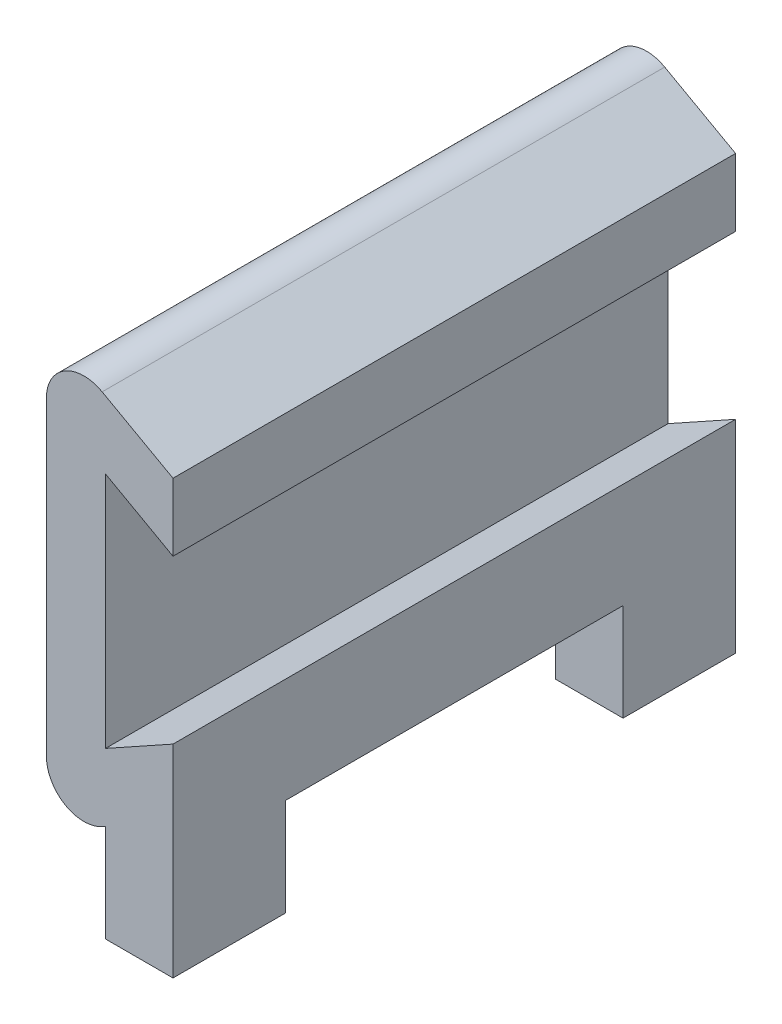
from build123d import *

# Parameters (mm, degrees)
BOSS_EXTRUDE1_DEPTH = 19.05
FILLET1_R           = 1.27
SKETCH3_W           = 2.286
SKETCH3_H           = 4.572
BOSS_EXTRUDE2_DEPTH = 19.05
SKETCH4_W           = 11.43
SKETCH4_H           = 3.302
CUT_EXTRUDE2_DEPTH  = 3.286


with BuildPart() as part:
    # Sketch2 → Boss-Extrude1 (new body)
    with BuildSketch(Plane.XY):
        Polygon((-50.411, 53.12524277), (-50.411, 61.17475723), (-48.125, 59.90475723), (-48.125, 62.192675039), (-52.411, 64.57378615), (-52.411, 49.72621385), (-48.125, 52.107324961), (-48.125, 54.39524277), align=None)
    extrude(amount=BOSS_EXTRUDE1_DEPTH)

    # Fillet1
    fillet1_edges = [part.edges().sort_by_distance(p)[0] for p in [
        (-52.411, 49.72621385, 9.525),
        (-52.411, 64.57378615, 9.525),
    ]]
    fillet(fillet1_edges, radius=FILLET1_R)

    # Sketch3 → Boss-Extrude2 (add, through all)
    with BuildSketch(Plane.XY.offset(19.05)):
        with Locations((-49.268, 49.821324961)):
            Rectangle(SKETCH3_W, SKETCH3_H)
    extrude(amount=-BOSS_EXTRUDE2_DEPTH)

    # Sketch4 → Cut-Extrude2 (cut, through all)
    with BuildSketch(Plane.ZY.offset(50.411)):
        with Locations((9.525, 49.186324961)):
            Rectangle(SKETCH4_W, SKETCH4_H)
    extrude(amount=-CUT_EXTRUDE2_DEPTH, mode=Mode.SUBTRACT)


solid = part.part
